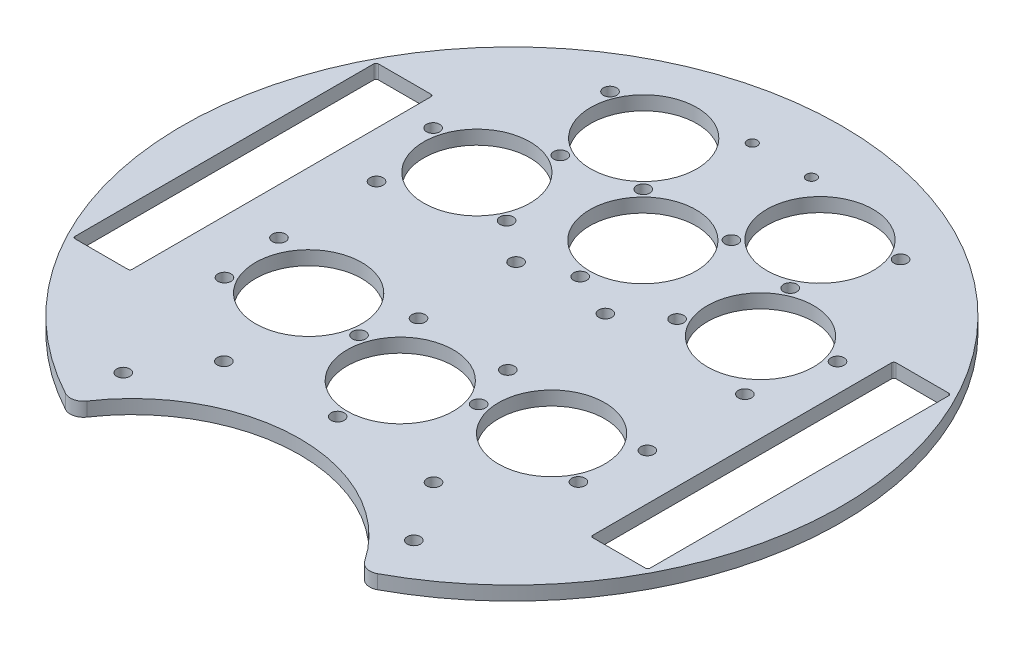
from build123d import *

# Parameters (mm, degrees)
SKETCH1_R           = 1.5
SKETCH1_R_2         = 12.095
SKETCH1_R_3         = 1.143
BOSS_EXTRUDE2_DEPTH = 3.175


with BuildPart() as part:
    # Sketch1 → Boss-Extrude2 (new body)
    with BuildSketch(Plane(origin=(0, 0, 0), x_dir=(1, 0, 0), z_dir=(0, 1, 0))):
        with BuildLine():
            ThreePointArc((31.589980006, -65.102164912), (33.357679643, -66.33740492), (35.49727084, -66.067721036))
            ThreePointArc((35.49727084, -66.067721036), (0, 75), (-35.49727084, -66.067721036))
            ThreePointArc((-35.49727084, -66.067721036), (-33.357679643, -66.33740492), (-31.589980006, -65.102164912))
            ThreePointArc((-31.589980006, -65.102164912), (0, -48.302004425), (31.589980006, -65.102164912))
        make_face()
        with Locations((-33.059737365, -55.383244446)):
            Circle(SKETCH1_R, mode=Mode.SUBTRACT)
        with Locations((-23.852486199, -41.694616163)):
            Circle(SKETCH1_R, mode=Mode.SUBTRACT)
        with Locations((0, -39.659190322)):
            Circle(SKETCH1_R, mode=Mode.SUBTRACT)
        with Locations((-40.277379234, -25.14022965)):
            Circle(SKETCH1_R, mode=Mode.SUBTRACT)
        with BuildLine():
            Line((-52.910067426, -34.5), (-64.910067426, -34.5))
            ThreePointArc((-64.910067426, -34.5), (-65.263620817, -34.353553391), (-65.410067426, -34))
            Line((-65.410067426, -34), (-65.410067426, 34))
            ThreePointArc((-65.410067426, 34), (-65.263620817, 34.353553391), (-64.910067426, 34.5))
            Line((-64.910067426, 34.5), (-52.910067426, 34.5))
            ThreePointArc((-52.910067426, 34.5), (-52.556514035, 34.353553391), (-52.410067426, 34))
            Line((-52.410067426, 34), (-52.410067426, -34))
            ThreePointArc((-52.410067426, -34), (-52.556514035, -34.353553391), (-52.910067426, -34.5))
        make_face(mode=Mode.SUBTRACT)
        with Locations((-41.910067426, -11.1)):
            Circle(SKETCH1_R, mode=Mode.SUBTRACT)
        with Locations((-27.645294552, -18.614761308)):
            Circle(SKETCH1_R_2, mode=Mode.SUBTRACT)
        with Locations((0, -25.409190322)):
            Circle(SKETCH1_R_2, mode=Mode.SUBTRACT)
        with Locations((-13.608916499, -21.183093811)):
            Circle(SKETCH1_R, mode=Mode.SUBTRACT)
        with Locations((-10.160067426, -11.1)):
            Circle(SKETCH1_R, mode=Mode.SUBTRACT)
        with Locations((33.059737365, -55.383244446)):
            Circle(SKETCH1_R, mode=Mode.SUBTRACT)
        with Locations((23.852486199, -41.694616163)):
            Circle(SKETCH1_R, mode=Mode.SUBTRACT)
        with Locations((13.608916499, -21.183093811)):
            Circle(SKETCH1_R, mode=Mode.SUBTRACT)
        with Locations((27.645294552, -18.614761308)):
            Circle(SKETCH1_R_2, mode=Mode.SUBTRACT)
        with Locations((10.160067426, -11.1)):
            Circle(SKETCH1_R, mode=Mode.SUBTRACT)
        with Locations((40.277379234, -25.14022965)):
            Circle(SKETCH1_R, mode=Mode.SUBTRACT)
        with Locations((41.910067426, -11.1)):
            Circle(SKETCH1_R, mode=Mode.SUBTRACT)
        with BuildLine():
            ThreePointArc((52.910067426, -34.5), (52.556514035, -34.353553391), (52.410067426, -34))
            Line((52.410067426, -34), (52.410067426, 34))
            ThreePointArc((52.410067426, 34), (52.556514035, 34.353553391), (52.910067426, 34.5))
            Line((52.910067426, 34.5), (64.910067426, 34.5))
            ThreePointArc((64.910067426, 34.5), (65.263620817, 34.353553391), (65.410067426, 34))
            Line((65.410067426, 34), (65.410067426, -34))
            ThreePointArc((65.410067426, -34), (65.263620817, -34.353553391), (64.910067426, -34.5))
            Line((64.910067426, -34.5), (52.910067426, -34.5))
        make_face(mode=Mode.SUBTRACT)
        with Locations((-41.910067426, 11.1)):
            Circle(SKETCH1_R, mode=Mode.SUBTRACT)
        with Locations((-46.011477091, 28.075890486)):
            Circle(SKETCH1_R, mode=Mode.SUBTRACT)
        with Locations((-19.397913834, 18.186588214)):
            Circle(SKETCH1_R, mode=Mode.SUBTRACT)
        with Locations((-10.160067426, 11.1)):
            Circle(SKETCH1_R, mode=Mode.SUBTRACT)
        with Locations((0, 15.543589551)):
            Circle(SKETCH1_R, mode=Mode.SUBTRACT)
        with Locations((-32.272094543, 24.295431891)):
            Circle(SKETCH1_R_2, mode=Mode.SUBTRACT)
        with Locations((-26.163250867, 37.1696126)):
            Circle(SKETCH1_R, mode=Mode.SUBTRACT)
        with Locations((0, 29.793589551)):
            Circle(SKETCH1_R_2, mode=Mode.SUBTRACT)
        with Locations((-33.059737365, 55.383244446)):
            Circle(SKETCH1_R, mode=Mode.SUBTRACT)
        with Locations((-20.05440719, 50.04379331)):
            Circle(SKETCH1_R_2, mode=Mode.SUBTRACT)
        with Locations((-10.027203595, 39.91869143)):
            Circle(SKETCH1_R, mode=Mode.SUBTRACT)
        with Locations((-6.731, 61.422565207)):
            Circle(SKETCH1_R_3, mode=Mode.SUBTRACT)
        with Locations((10.160067426, 11.1)):
            Circle(SKETCH1_R, mode=Mode.SUBTRACT)
        with Locations((19.397913834, 18.186588214)):
            Circle(SKETCH1_R, mode=Mode.SUBTRACT)
        with Locations((32.272094543, 24.295431891)):
            Circle(SKETCH1_R_2, mode=Mode.SUBTRACT)
        with Locations((26.163250867, 37.1696126)):
            Circle(SKETCH1_R, mode=Mode.SUBTRACT)
        with Locations((41.910067426, 11.1)):
            Circle(SKETCH1_R, mode=Mode.SUBTRACT)
        with Locations((46.011477091, 28.075890486)):
            Circle(SKETCH1_R, mode=Mode.SUBTRACT)
        with Locations((10.027203595, 39.91869143)):
            Circle(SKETCH1_R, mode=Mode.SUBTRACT)
        with Locations((20.05440719, 50.04379331)):
            Circle(SKETCH1_R_2, mode=Mode.SUBTRACT)
        with Locations((33.059737365, 55.383244446)):
            Circle(SKETCH1_R, mode=Mode.SUBTRACT)
        with Locations((6.731, 61.422565207)):
            Circle(SKETCH1_R_3, mode=Mode.SUBTRACT)
    extrude(amount=BOSS_EXTRUDE2_DEPTH)


solid = part.part
